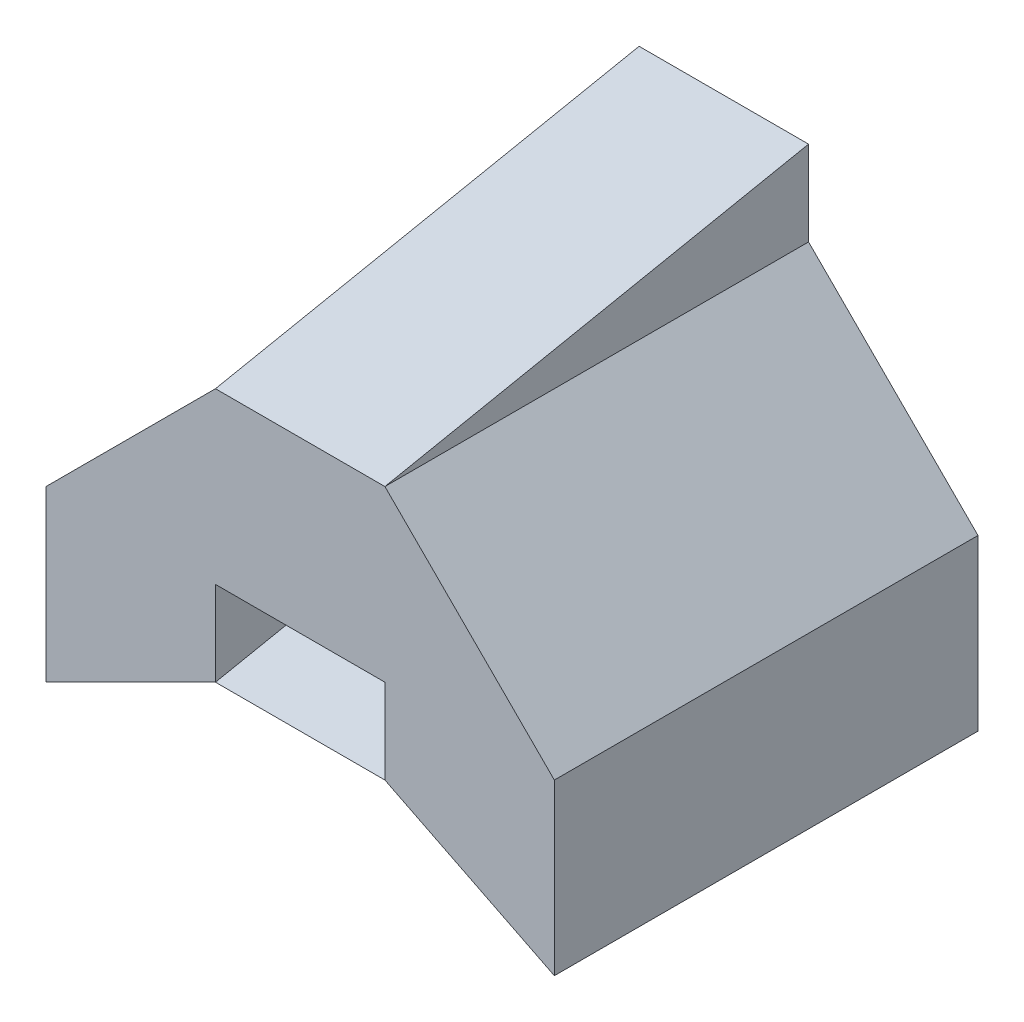
from build123d import *

# Parameters (mm, degrees)
BOSS_EXTRUDE1_DEPTH = 25
CUT_EXTRUDE1_DEPTH  = 25
BOSS_EXTRUDE3_DEPTH = 10


with BuildPart() as part:
    # Sketch1 → Boss-Extrude1 (new body)
    with BuildSketch(Plane.XY):
        Polygon((-10, 15), (-10, 20), (0, 20), (0, 15), (10, 5), (10, -5), (0, 0), (0, 5), (-10, 5), (-10, 0), (-20, -5), (-20, 5), align=None)
    extrude(amount=BOSS_EXTRUDE1_DEPTH)

    # Sketch2 → Cut-Extrude1 (cut)
    with BuildSketch(Plane(origin=(0, 0, 0), x_dir=(0, 0, -1), z_dir=(1, 0, 0))):
        Polygon((-25, 15), (0, 20), (-25, 20), align=None)
    extrude(amount=-CUT_EXTRUDE1_DEPTH, mode=Mode.SUBTRACT)


with BuildPart() as body_2:
    # Sketch3 → Boss-Extrude3 (new body)
    with BuildSketch(Plane(origin=(-10, 0, 0), x_dir=(0, 0, -1), z_dir=(1, 0, 0))):
        Polygon((-25, 0), (0, 5), (0, 0), align=None)
    extrude(amount=BOSS_EXTRUDE3_DEPTH)


solid = Compound([part.part, body_2.part])
